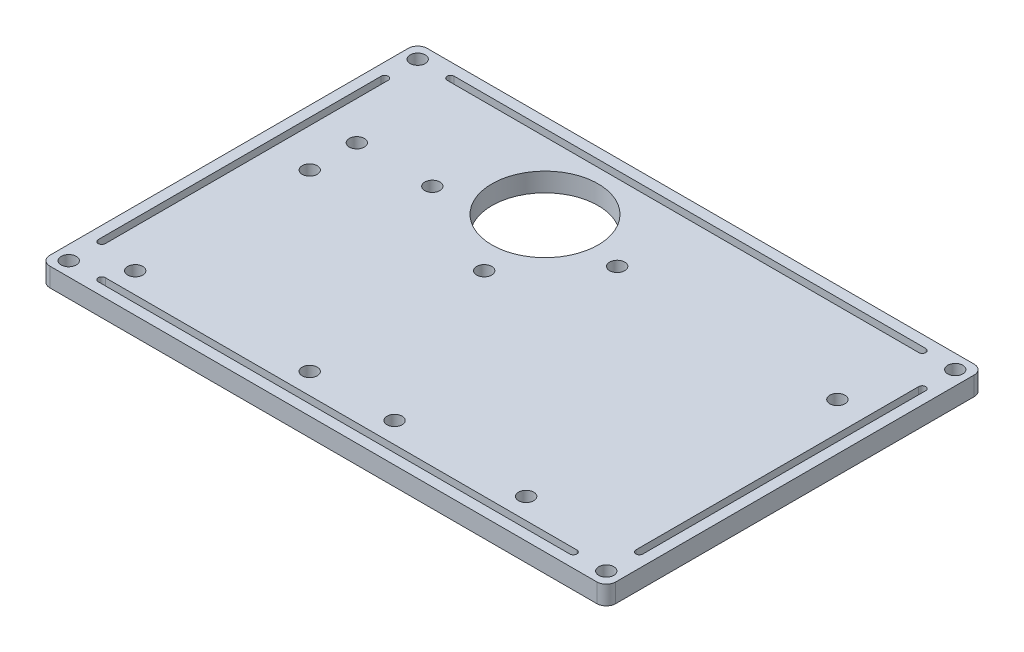
from build123d import *

# Parameters (mm, degrees)
SKETCH1_W           = 120
SKETCH1_H           = 80
SKETCH1_R           = 1.6
SKETCH1_R_2         = 11.25
BOSS_EXTRUDE3_DEPTH = 4
FILLET5_R           = 2
FILLET6_R           = 2
FILLET7_R           = 2
FILLET8_R           = 2


with BuildPart() as part:
    # Sketch1 → Boss-Extrude3 (new body)
    with BuildSketch(Plane(origin=(0, 0, 0), x_dir=(1, 0, 0), z_dir=(0, 1, 0))):
        with Locations((60, 40)):
            Rectangle(SKETCH1_W, SKETCH1_H)
        with Locations((3, 77)):
            Circle(SKETCH1_R, mode=Mode.SUBTRACT)
        with Locations((3, 3)):
            Circle(SKETCH1_R, mode=Mode.SUBTRACT)
        with Locations((117, 77)):
            Circle(SKETCH1_R, mode=Mode.SUBTRACT)
        with Locations((117, 3)):
            Circle(SKETCH1_R, mode=Mode.SUBTRACT)
        with Locations((110, 59)):
            Circle(SKETCH1_R, mode=Mode.SUBTRACT)
        with Locations((94.8, 8.2)):
            Circle(SKETCH1_R, mode=Mode.SUBTRACT)
        with Locations((66.9, 8.2)):
            Circle(SKETCH1_R, mode=Mode.SUBTRACT)
        with Locations((11.9, 8.2)):
            Circle(SKETCH1_R, mode=Mode.SUBTRACT)
        with Locations((48.9, 8.2)):
            Circle(SKETCH1_R, mode=Mode.SUBTRACT)
        with Locations((11.9, 45.2)):
            Circle(SKETCH1_R, mode=Mode.SUBTRACT)
        with Locations((48.9, 45.2)):
            Circle(SKETCH1_R, mode=Mode.SUBTRACT)
        with Locations((11.9, 55.2)):
            Circle(SKETCH1_R, mode=Mode.SUBTRACT)
        with Locations((27.9, 55.2)):
            Circle(SKETCH1_R, mode=Mode.SUBTRACT)
        with Locations((45, 62)):
            Circle(SKETCH1_R_2, mode=Mode.SUBTRACT)
        with Locations((62.2, 60.1)):
            Circle(SKETCH1_R, mode=Mode.SUBTRACT)
        with BuildLine():
            Line((10, 77.75), (110, 77.75))
            ThreePointArc((110, 77.75), (110.75, 77), (110, 76.25))
            Line((110, 76.25), (10, 76.25))
            ThreePointArc((10, 76.25), (9.25, 77), (10, 77.75))
        make_face(mode=Mode.SUBTRACT)
        with BuildLine():
            Line((3.75, 70), (3.75, 10))
            ThreePointArc((3.75, 10), (3, 9.25), (2.25, 10))
            Line((2.25, 10), (2.25, 70))
            ThreePointArc((2.25, 70), (3, 70.75), (3.75, 70))
        make_face(mode=Mode.SUBTRACT)
        with BuildLine():
            Line((10, 3.75), (110, 3.75))
            ThreePointArc((110, 3.75), (110.75, 3), (110, 2.25))
            Line((110, 2.25), (10, 2.25))
            ThreePointArc((10, 2.25), (9.25, 3), (10, 3.75))
        make_face(mode=Mode.SUBTRACT)
        with BuildLine():
            Line((117.75, 70), (117.75, 10))
            ThreePointArc((117.75, 10), (117, 9.25), (116.25, 10))
            Line((116.25, 10), (116.25, 70))
            ThreePointArc((116.25, 70), (117, 70.75), (117.75, 70))
        make_face(mode=Mode.SUBTRACT)
    extrude(amount=BOSS_EXTRUDE3_DEPTH)

    # Fillet5
    fillet5_edges = [part.edges().sort_by_distance(p)[0] for p in [
        (0, 2, 0),
    ]]
    fillet(fillet5_edges, radius=FILLET5_R)

    # Fillet6
    fillet6_edges = [part.edges().sort_by_distance(p)[0] for p in [
        (0, 2, -80),
    ]]
    fillet(fillet6_edges, radius=FILLET6_R)

    # Fillet7
    fillet7_edges = [part.edges().sort_by_distance(p)[0] for p in [
        (120, 2, -80),
    ]]
    fillet(fillet7_edges, radius=FILLET7_R)

    # Fillet8
    fillet8_edges = [part.edges().sort_by_distance(p)[0] for p in [
        (120, 2, 0),
    ]]
    fillet(fillet8_edges, radius=FILLET8_R)


solid = part.part
